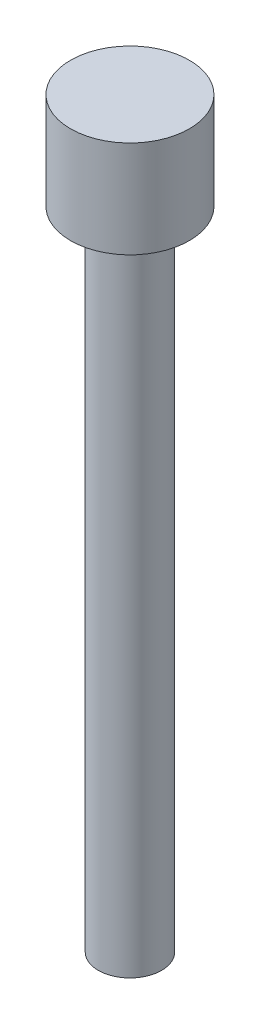
from build123d import *

# Parameters (mm, degrees)
SKETCH1_R           = 1.84
BOSS_EXTRUDE1_DEPTH = 3
SKETCH2_R           = 0.98
BOSS_EXTRUDE2_DEPTH = 20


with BuildPart() as part:
    # Sketch1 → Boss-Extrude1 (new body)
    with BuildSketch(Plane(origin=(0, 0, 0), x_dir=(1, 0, 0), z_dir=(0, 1, 0))):
        Circle(SKETCH1_R)
    extrude(amount=BOSS_EXTRUDE1_DEPTH)

    # Sketch2 → Boss-Extrude2 (add)
    with BuildSketch(Plane.XZ):
        Circle(SKETCH2_R)
    extrude(amount=BOSS_EXTRUDE2_DEPTH)


solid = part.part
